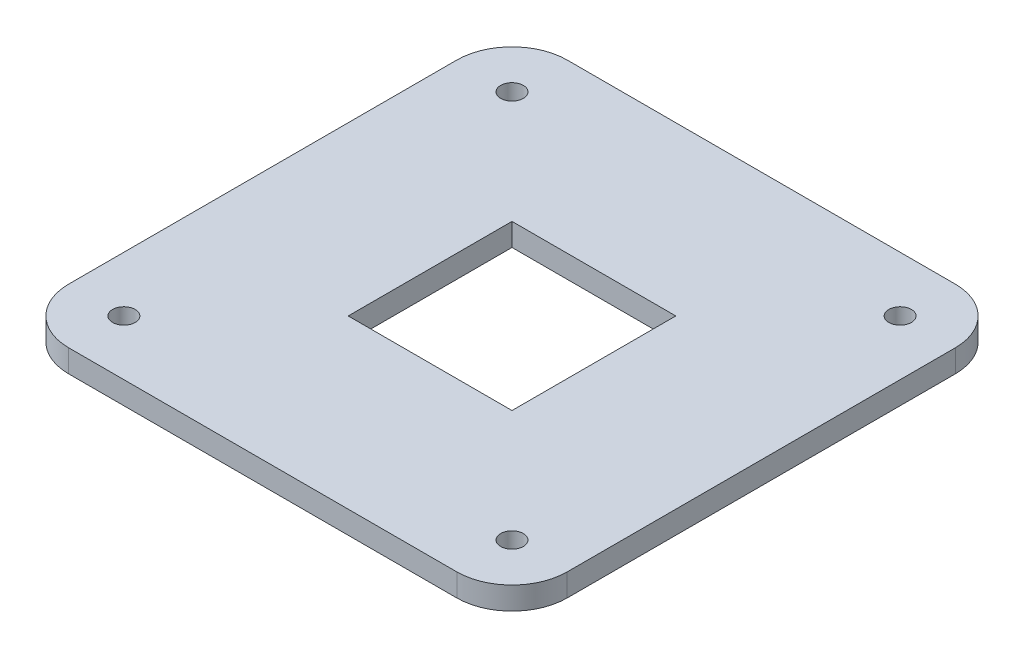
from build123d import *

# Parameters (mm, degrees)
CROQUIS1_R              = 6.35
CROQUIS1_W              = 92
CROQUIS1_H              = 92
SALIENTE_EXTRUIR1_DEPTH = 12.7


with BuildPart() as part:
    # Croquis1 → Saliente-Extruir1 (new body)
    with BuildSketch(Plane(origin=(0, 0, 0), x_dir=(1, 0, 0), z_dir=(0, 1, 0))):
        with BuildLine():
            Line((-109, 140), (109, 140))
            ThreePointArc((109, 140), (130.920310217, 130.920310217), (140, 109))
            Line((140, 109), (140, -109))
            ThreePointArc((140, -109), (130.920310217, -130.920310217), (109, -140))
            Line((109, -140), (-109, -140))
            ThreePointArc((-109, -140), (-130.920310217, -130.920310217), (-140, -109))
            Line((-140, -109), (-140, 109))
            ThreePointArc((-140, 109), (-130.920310217, 130.920310217), (-109, 140))
        make_face()
        with Locations((-109, -109)):
            Circle(CROQUIS1_R, mode=Mode.SUBTRACT)
        with Locations((-109, 109)):
            Circle(CROQUIS1_R, mode=Mode.SUBTRACT)
        with Locations((109, 109)):
            Circle(CROQUIS1_R, mode=Mode.SUBTRACT)
        with Locations((109, -109)):
            Circle(CROQUIS1_R, mode=Mode.SUBTRACT)
        Rectangle(CROQUIS1_W, CROQUIS1_H, mode=Mode.SUBTRACT)
    extrude(amount=SALIENTE_EXTRUIR1_DEPTH)


solid = part.part
